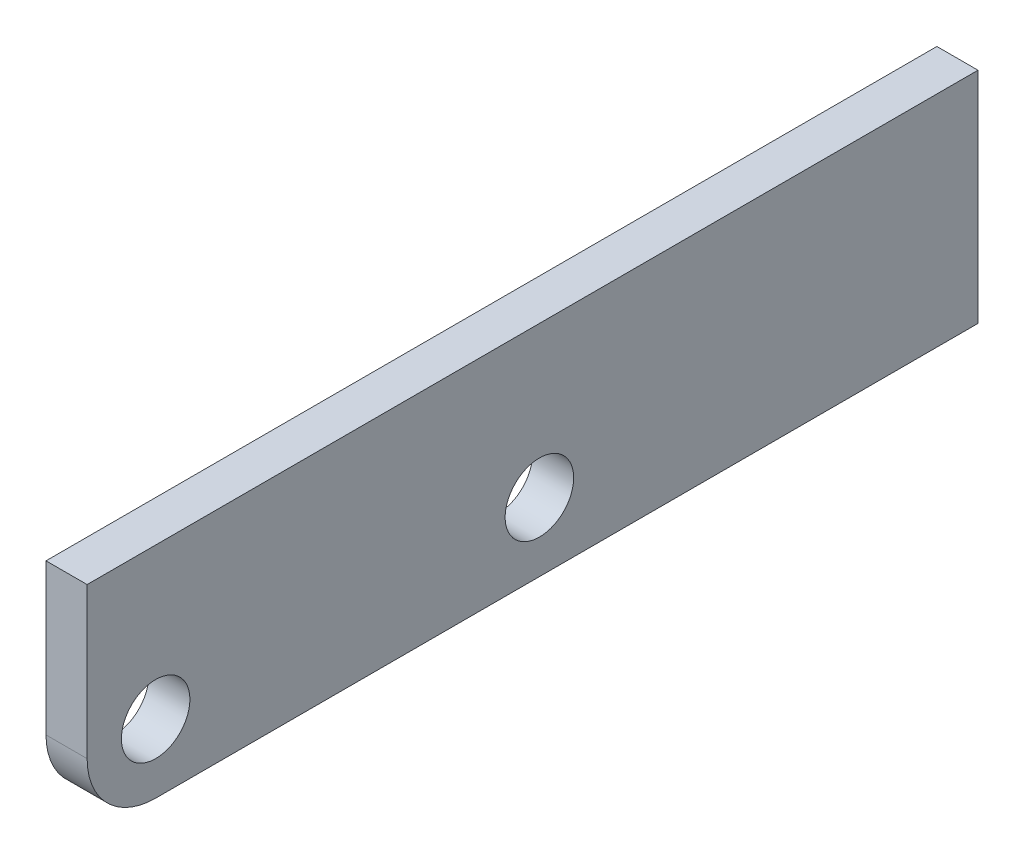
from build123d import *

# Parameters (mm, degrees)
SKETCH1_W           = 412.75
SKETCH1_H           = 101.6
BOSS_EXTRUDE1_DEPTH = 9.525
CUT_EXTRUDE1_REACH  = 21.05
SKETCH2_R           = 15.875
FILLET1_R           = 31.75


with BuildPart() as part:
    # Sketch1 → Boss-Extrude1 (new body, symmetric)
    with BuildSketch(Plane(origin=(0, 0, 0), x_dir=(0, 0, -1), z_dir=(1, 0, 0))):
        Rectangle(SKETCH1_W, SKETCH1_H)
    extrude(amount=BOSS_EXTRUDE1_DEPTH, both=True)

    # Sketch2 → Cut-Extrude1 (cut, up to next)
    with BuildSketch(Plane(origin=(9.525, 0, 0), x_dir=(0, 0, -1), z_dir=(1, 0, 0)), mode=Mode.PRIVATE) as cut_extrude1_sk1:
        with Locations((-174.625, -19.05)):
            Circle(SKETCH2_R)
    cut_extrude1_tool1 = extrude(cut_extrude1_sk1.sketch, amount=-CUT_EXTRUDE1_REACH, mode=Mode.PRIVATE) & part.part
    add(cut_extrude1_tool1.solids().sort_by_distance((9.525, -19.05, 174.625))[0], mode=Mode.SUBTRACT)
    # Sketch2 → Cut-Extrude1 (cut, up to next)
    with BuildSketch(Plane(origin=(9.525, 0, 0), x_dir=(0, 0, -1), z_dir=(1, 0, 0)), mode=Mode.PRIVATE) as cut_extrude1_sk2:
        with Locations((3.175, -19.05)):
            Circle(SKETCH2_R)
    cut_extrude1_tool2 = extrude(cut_extrude1_sk2.sketch, amount=-CUT_EXTRUDE1_REACH, mode=Mode.PRIVATE) & part.part
    add(cut_extrude1_tool2.solids().sort_by_distance((9.525, -19.05, -3.175))[0], mode=Mode.SUBTRACT)

    # Fillet1
    fillet1_edges = [part.edges().sort_by_distance(p)[0] for p in [
        (0, -50.8, 206.375),
    ]]
    fillet(fillet1_edges, radius=FILLET1_R)


solid = part.part
